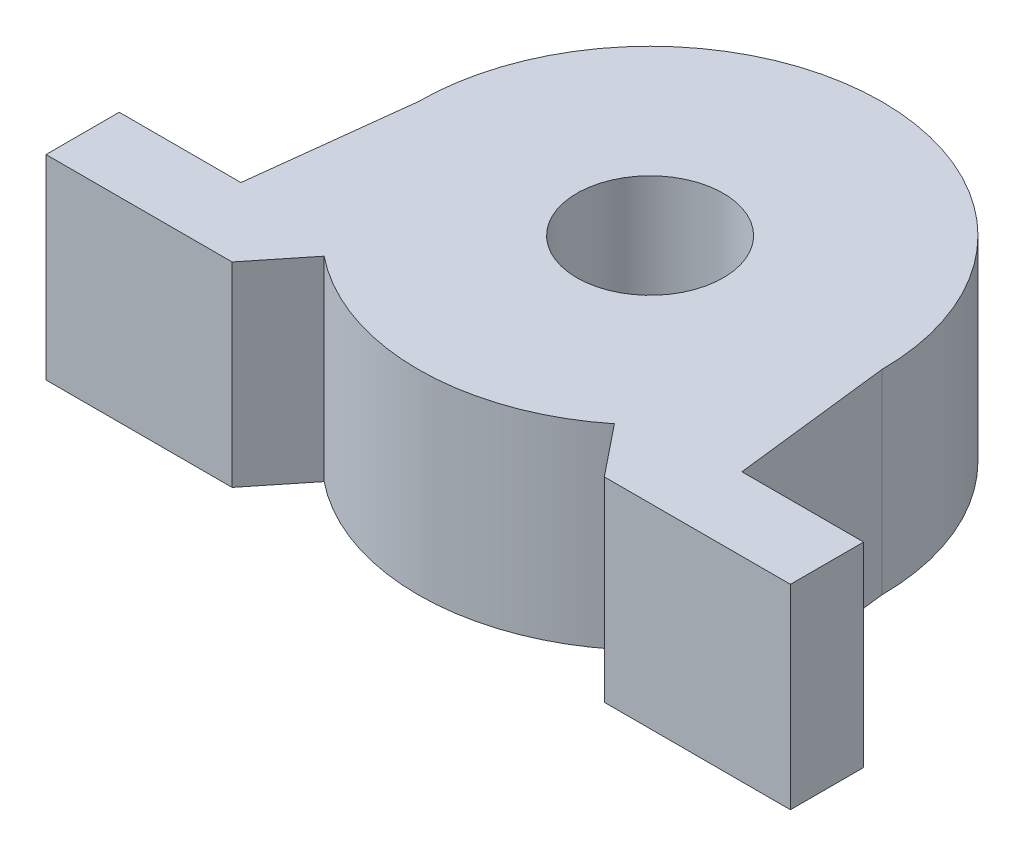
from build123d import *

# Parameters (mm, degrees)
SKETCH2_R           = 6
BOSS_EXTRUDE2_DEPTH = 16


with BuildPart() as part:
    # Sketch2 → Boss-Extrude2 (new body)
    with BuildSketch(Plane(origin=(0, 0, 0), x_dir=(1, 0, 0), z_dir=(0, 1, 0))):
        with BuildLine():
            Line((-15.25, -19), (-30.5, -19))
            Line((-30.5, -19), (-30.5, -13))
            Line((-30.5, -13), (-20.524290918, -13))
            Line((-20.524290918, -13), (-19, 0))
            ThreePointArc((-19, 0), (0, 19), (19, 0))
            Line((19, 0), (20.524290918, -13))
            Line((20.524290918, -13), (30.5, -13))
            Line((30.5, -13), (30.5, -19))
            Line((30.5, -19), (15.25, -19))
            Line((15.25, -19), (11.892967086, -14.817467189))
            ThreePointArc((11.892967086, -14.817467189), (0, -19), (-11.892967086, -14.817467189))
            Line((-11.892967086, -14.817467189), (-15.25, -19))
        make_face()
        Circle(SKETCH2_R, mode=Mode.SUBTRACT)
    extrude(amount=BOSS_EXTRUDE2_DEPTH)


solid = part.part
